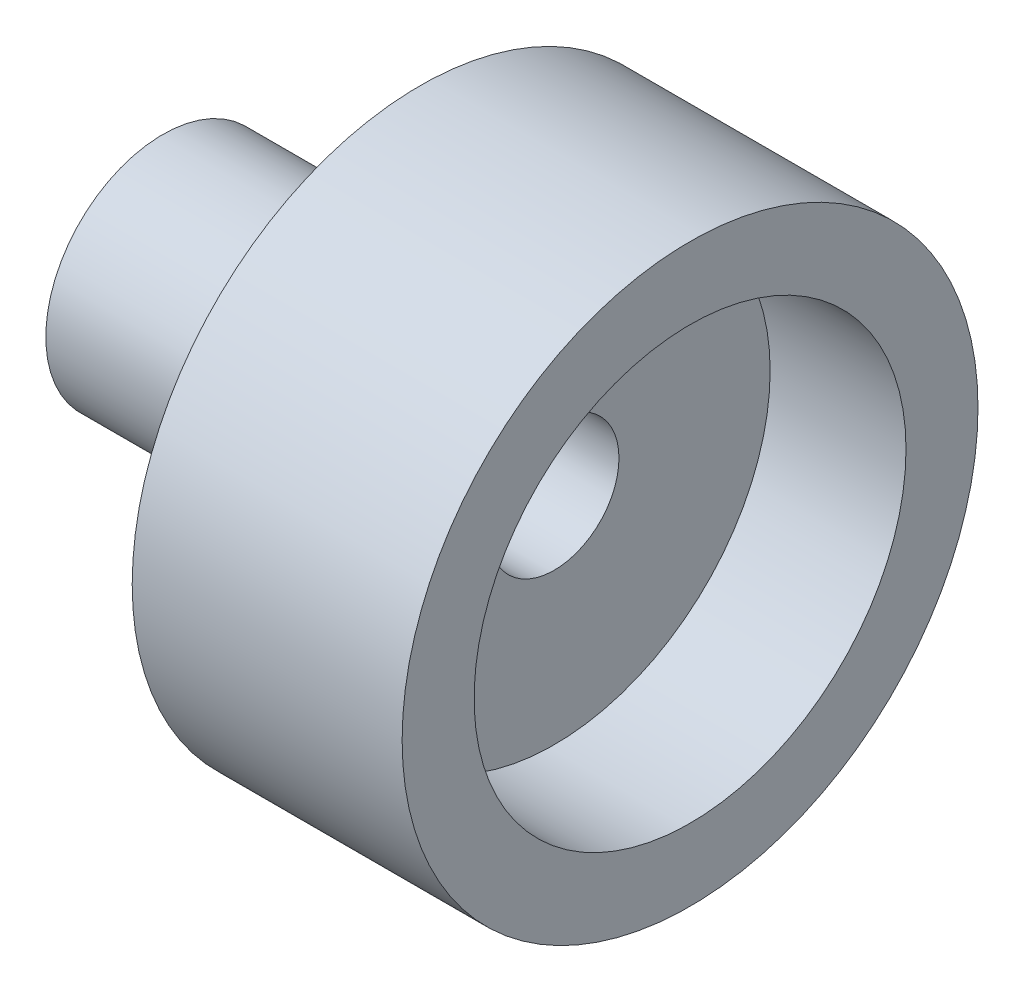
from build123d import *

# Parameters (mm, degrees)
SKETCH2_R           = 8
SKETCH2_R_2         = 3.25
BOSS_EXTRUDE1_DEPTH = 7.5
SKETCH3_R           = 6
CUT_EXTRUDE1_DEPTH  = 3.775
SKETCH4_R           = 3.25
SKETCH4_R_2         = 1.8
BOSS_EXTRUDE2_DEPTH = 10.875


with BuildPart() as part:
    # Sketch2 → Boss-Extrude1 (new body)
    with BuildSketch(Plane(origin=(0, 0, 0), x_dir=(0, 0, -1), z_dir=(1, 0, 0))):
        Circle(SKETCH2_R)
        Circle(SKETCH2_R_2, mode=Mode.SUBTRACT)
    extrude(amount=BOSS_EXTRUDE1_DEPTH)

    # Sketch3 → Cut-Extrude1 (cut)
    with BuildSketch(Plane(origin=(7.5, 0, 0), x_dir=(0, 0, -1), z_dir=(1, 0, 0))):
        Circle(SKETCH3_R)
    extrude(amount=-CUT_EXTRUDE1_DEPTH, mode=Mode.SUBTRACT)

    # Sketch4 → Boss-Extrude2 (add)
    with BuildSketch(Plane(origin=(3.725, 0, 0), x_dir=(0, 0, -1), z_dir=(1, 0, 0))):
        Circle(SKETCH4_R)
        Circle(SKETCH4_R_2, mode=Mode.SUBTRACT)
    extrude(amount=-BOSS_EXTRUDE2_DEPTH)


solid = part.part
